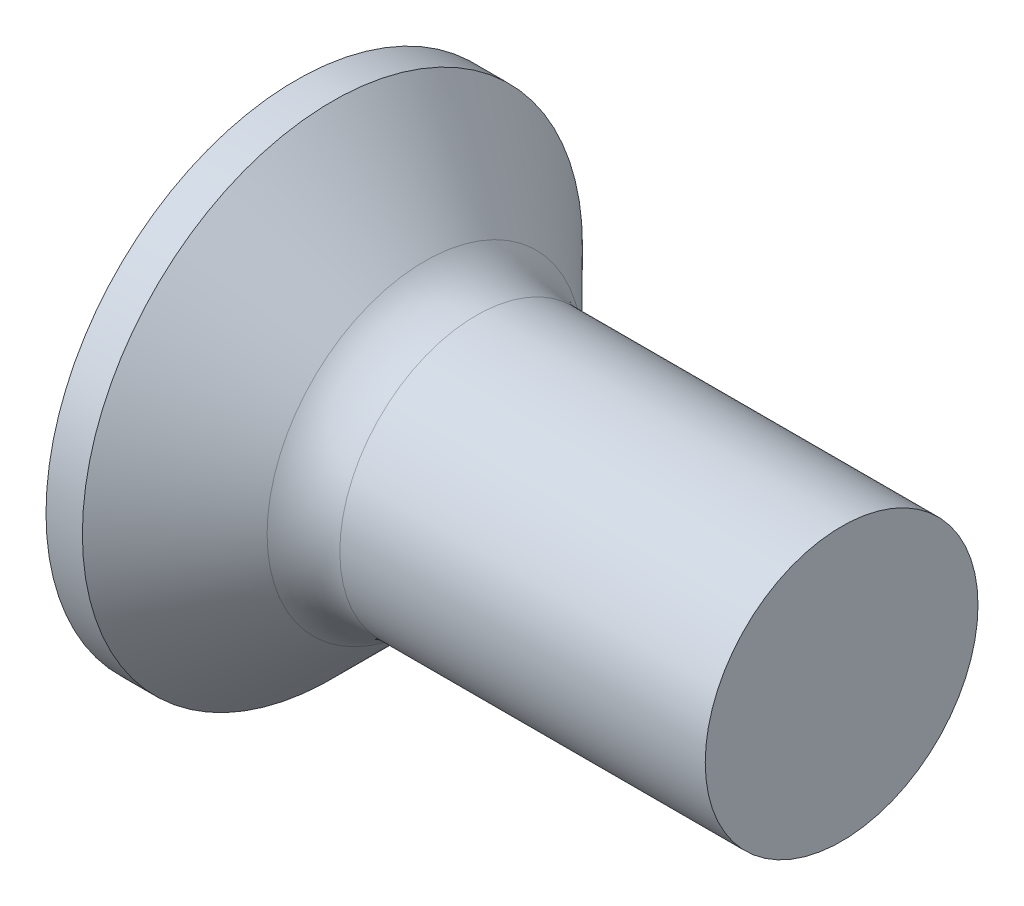
from build123d import *

# Parameters (mm, degrees)
FILLET1_R    = 0.8
SKETCH3_W    = 0.74
SKETCH3_H    = 3
SKETCH4_W    = 0.74
SKETCH4_H    = 0.995702004
RECPAT_COUNT = 2
RECPAT_ANGLE = 90


with BuildPart() as part:
    # BodySke → Base-Revolve (revolve)
    with BuildSketch(Plane.XY):
        Polygon((0, 0), (0, 2.75), (0.4, 2.75), (1.65, 1.5), (6, 1.5), (6, 0), align=None)
    revolve(axis=Axis((-6.35, 0, 0), (1, 0, 0)))

    # Fillet1
    fillet1_edges = [part.edges().sort_by_distance(p)[0] for p in [
        (1.65, -1.5, 0),
    ]]
    fillet(fillet1_edges, radius=FILLET1_R)

    # Sketch3 → Recess section 0
    with BuildSketch(Plane.ZY):
        Rectangle(SKETCH3_W, SKETCH3_H)
    # Sketch4 → Recess section 1
    with BuildSketch(Plane.ZY.offset(-2.01)):
        Rectangle(SKETCH4_W, SKETCH4_H)
    recess = loft(mode=Mode.SUBTRACT)

    # RecPat: Recess ×2 about axis
    recpat_axis = Axis((0, 0, 0), (1, 0, 0))
    for i in range(1, RECPAT_COUNT):
        add(recess.rotate(recpat_axis, i * RECPAT_ANGLE / (RECPAT_COUNT - 1)), mode=Mode.SUBTRACT)

    # RecCorSke → RecessCore (revolve, cut)
    with BuildSketch(Plane.XY):
        Polygon((0, 0), (0, 0.696552892), (2.01, 0.556), (2.190655351, 0), align=None)
    revolve(axis=Axis((-3.175, 0, 0), (1, 0, 0)), mode=Mode.SUBTRACT)


solid = part.part
